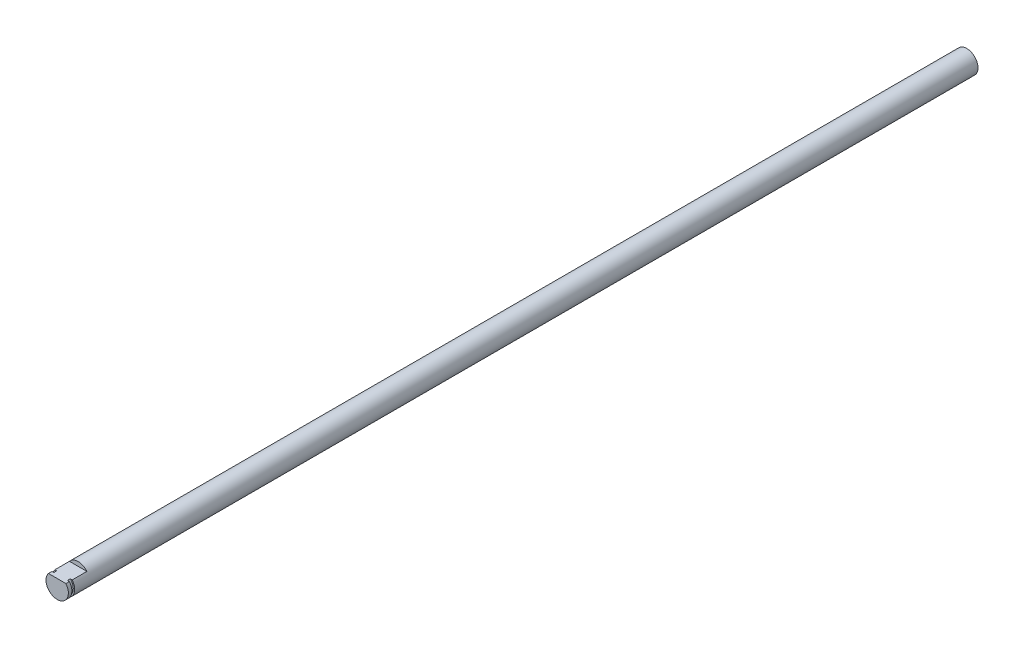
from build123d import *

# Parameters (mm, degrees)
SKETCH1_R           = 4
BOSS_EXTRUDE1_DEPTH = 325
CUT_EXTRUDE1_DEPTH  = 7.5
SKETCH3_R           = 4
SKETCH3_R_2         = 3.5
CUT_EXTRUDE2_DEPTH  = 1


with BuildPart() as part:
    # Sketch1 → Boss-Extrude1 (new body)
    with BuildSketch(Plane.XY):
        Circle(SKETCH1_R)
    extrude(amount=BOSS_EXTRUDE1_DEPTH)

    # Sketch2 → Cut-Extrude1 (cut)
    with BuildSketch(Plane.XY.offset(325)):
        with BuildLine():
            Line((3.122498999, 2.5), (-3.122498999, 2.5))
            ThreePointArc((-3.122498999, 2.5), (0, 4), (3.122498999, 2.5))
        make_face()
    extrude(amount=-CUT_EXTRUDE1_DEPTH, mode=Mode.SUBTRACT)

    # Sketch3 → Cut-Extrude2 (cut)
    with BuildSketch(Plane.XY.offset(323.75)):
        Circle(SKETCH3_R)
        Circle(SKETCH3_R_2, mode=Mode.SUBTRACT)
    extrude(amount=-CUT_EXTRUDE2_DEPTH, mode=Mode.SUBTRACT)


solid = part.part
